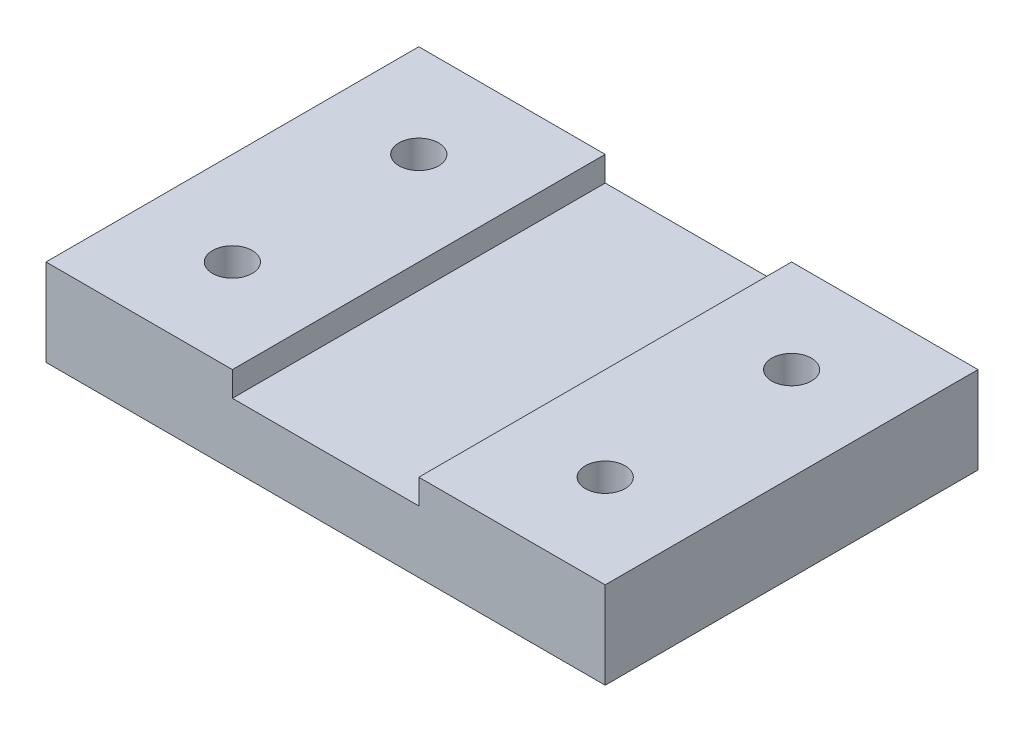
from build123d import *

# Parameters (mm, degrees)
SKETCH1_W             = 15
SKETCH1_H             = 30
SKETCH1_R             = 1.6
BOSS_EXTRUDE1_DEPTH   = 7
BOSS_EXTRUDE1_2_DEPTH = 7
SKETCH1_3_W           = 15
SKETCH1_3_H           = 30
BOSS_EXTRUDE2_DEPTH   = 5


with BuildPart() as part:
    # Sketch1 → Boss-Extrude1 (new body)
    with BuildSketch(Plane(origin=(0, 0, 0), x_dir=(1, 0, 0), z_dir=(0, 1, 0))):
        with Locations((-15, 0)):
            Rectangle(SKETCH1_W, SKETCH1_H)
        with Locations((-15, -7.5)):
            Circle(SKETCH1_R, mode=Mode.SUBTRACT)
        with Locations((-15, 7.5)):
            Circle(SKETCH1_R, mode=Mode.SUBTRACT)
    extrude(amount=BOSS_EXTRUDE1_DEPTH)



with BuildPart() as body_2:
    # Sketch1 → Boss-Extrude1 2 (new body)
    with BuildSketch(Plane(origin=(0, 0, 0), x_dir=(1, 0, 0), z_dir=(0, 1, 0))):
        with Locations((15, 0)):
            Rectangle(SKETCH1_W, SKETCH1_H)
        with Locations((15, -7.5)):
            Circle(SKETCH1_R, mode=Mode.SUBTRACT)
        with Locations((15, 7.5)):
            Circle(SKETCH1_R, mode=Mode.SUBTRACT)
    extrude(amount=BOSS_EXTRUDE1_2_DEPTH)


with BuildPart() as part_1:
    add(part.part)

    add(body_2.part)  # Boss-Extrude2 merges body 2
    # Sketch1_3 → Boss-Extrude2 (add)
    with BuildSketch(Plane(origin=(0, 0, 0), x_dir=(1, 0, 0), z_dir=(0, 1, 0))):
        Rectangle(SKETCH1_3_W, SKETCH1_3_H)
    extrude(amount=BOSS_EXTRUDE2_DEPTH)


solid = part_1.part
